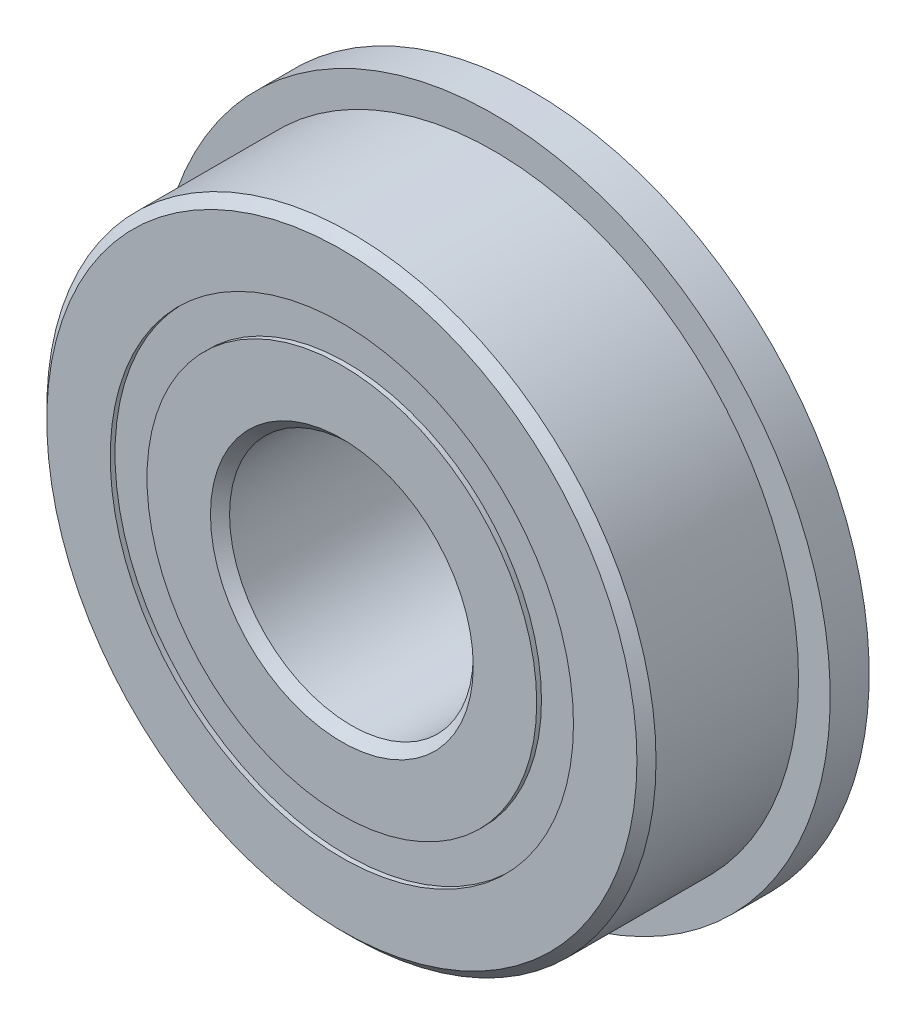
from build123d import *

# Parameters (mm, degrees)
CIRPATTERN1_COUNT = 14
SKETCH5_W         = 1.15919535
SKETCH5_H         = 0.957942858
SKETCH6_W         = 1.016
SKETCH6_H         = 2.727778571


with BuildPart() as part:
    # Sketch1 → Revolve1 (revolve)
    with BuildSketch(Plane(origin=(0, 0, 0), x_dir=(0, 0, -1), z_dir=(1, 0, 0)), mode=Mode.PRIVATE) as revolve1_sk:
        with BuildLine():
            Line((2.24028, 7.9375), (-2.24028, 7.9375))
            Line((-2.24028, 7.9375), (-2.4892, 7.68858))
            Line((-2.4892, 7.68858), (-2.4892, 6.035221429))
            Line((-2.4892, 6.035221429), (-1.106311111, 6.035221429))
            ThreePointArc((-1.106311111, 6.035221429), (0, 6.76179465), (1.106311111, 6.035221429))
            Line((1.106311111, 6.035221429), (2.4892, 6.035221429))
            Line((2.4892, 6.035221429), (2.4892, 7.68858))
            Line((2.4892, 7.68858), (2.24028, 7.9375))
        make_face()
    revolve(revolve1_sk.sketch.rotate(Axis((0, 0, 2.4892), (0, 0, -1)), 90), axis=Axis((0, 0, 2.4892), (0, 0, -1)))  # turned: the seam where the file's is

    # Sketch6 → Revolve6 (revolve)
    with BuildSketch(Plane(origin=(0, 0, 0), x_dir=(0, 0, -1), z_dir=(1, 0, 0)), mode=Mode.PRIVATE) as revolve6_sk:
        with Locations((1.9812, 7.399110715)):
            Rectangle(SKETCH6_W, SKETCH6_H)
    revolve(revolve6_sk.sketch.rotate(Axis((0, 0, -2.4892), (0, 0, 1)), 270), axis=Axis((0, 0, -2.4892), (0, 0, 1)))  # turned: the seam where the file's is


with BuildPart() as body_2:
    # Sketch3 → Revolve3 (revolve)
    with BuildSketch(Plane(origin=(0, 0, 0), x_dir=(0, 0, -1), z_dir=(1, 0, 0)), mode=Mode.PRIVATE) as revolve3_sk:
        with BuildLine():
            Line((-2.4892, 5.077278571), (-1.106311111, 5.077278571))
            ThreePointArc((-1.106311111, 5.077278571), (0, 4.35070535), (1.106311111, 5.077278571))
            Line((1.106311111, 5.077278571), (2.4892, 5.077278571))
            Line((2.4892, 5.077278571), (2.4892, 3.42392))
            Line((2.4892, 3.42392), (2.24028, 3.175))
            Line((2.24028, 3.175), (-2.24028, 3.175))
            Line((-2.24028, 3.175), (-2.4892, 3.42392))
            Line((-2.4892, 3.42392), (-2.4892, 5.077278571))
        make_face()
    revolve(revolve3_sk.sketch.rotate(Axis((0, 0, 2.4892), (0, 0, -1)), 90), axis=Axis((0, 0, 2.4892), (0, 0, -1)))  # turned: the seam where the file's is


with BuildPart() as body_3:
    # Sketch4 → Revolve4 (revolve)
    with BuildSketch(Plane(origin=(0, 0, 0), x_dir=(0, 0, -1), z_dir=(1, 0, 0))):
        with BuildLine():
            Line((-1.20554465, 5.55625), (1.20554465, 5.55625))
            ThreePointArc((1.20554465, 5.55625), (0, 6.76179465), (-1.20554465, 5.55625))
        make_face()
    revolve(axis=Axis((0, 5.55625, 1.20554465), (0, 0, -1)))


with BuildPart() as cirpattern1_1:
    # CirPattern1: pattern copy
    add(body_3.part.rotate(Axis((0, 0, 0), (0, 0, 1)), 1 * 360 / CIRPATTERN1_COUNT))


with BuildPart() as cirpattern1_2:
    # CirPattern1: pattern copy
    add(body_3.part.rotate(Axis((0, 0, 0), (0, 0, 1)), 2 * 360 / CIRPATTERN1_COUNT))


with BuildPart() as cirpattern1_3:
    # CirPattern1: pattern copy
    add(body_3.part.rotate(Axis((0, 0, 0), (0, 0, 1)), 3 * 360 / CIRPATTERN1_COUNT))


with BuildPart() as cirpattern1_4:
    # CirPattern1: pattern copy
    add(body_3.part.rotate(Axis((0, 0, 0), (0, 0, 1)), 4 * 360 / CIRPATTERN1_COUNT))


with BuildPart() as cirpattern1_5:
    # CirPattern1: pattern copy
    add(body_3.part.rotate(Axis((0, 0, 0), (0, 0, 1)), 5 * 360 / CIRPATTERN1_COUNT))


with BuildPart() as cirpattern1_6:
    # CirPattern1: pattern copy
    add(body_3.part.rotate(Axis((0, 0, 0), (0, 0, 1)), 6 * 360 / CIRPATTERN1_COUNT))


with BuildPart() as cirpattern1_7:
    # CirPattern1: pattern copy
    add(body_3.part.rotate(Axis((0, 0, 0), (0, 0, 1)), 7 * 360 / CIRPATTERN1_COUNT))


with BuildPart() as cirpattern1_8:
    # CirPattern1: pattern copy
    add(body_3.part.rotate(Axis((0, 0, 0), (0, 0, 1)), 8 * 360 / CIRPATTERN1_COUNT))


with BuildPart() as cirpattern1_9:
    # CirPattern1: pattern copy
    add(body_3.part.rotate(Axis((0, 0, 0), (0, 0, 1)), 9 * 360 / CIRPATTERN1_COUNT))


with BuildPart() as cirpattern1_10:
    # CirPattern1: pattern copy
    add(body_3.part.rotate(Axis((0, 0, 0), (0, 0, 1)), 10 * 360 / CIRPATTERN1_COUNT))


with BuildPart() as cirpattern1_11:
    # CirPattern1: pattern copy
    add(body_3.part.rotate(Axis((0, 0, 0), (0, 0, 1)), 11 * 360 / CIRPATTERN1_COUNT))


with BuildPart() as cirpattern1_12:
    # CirPattern1: pattern copy
    add(body_3.part.rotate(Axis((0, 0, 0), (0, 0, 1)), 12 * 360 / CIRPATTERN1_COUNT))


with BuildPart() as cirpattern1_13:
    # CirPattern1: pattern copy
    add(body_3.part.rotate(Axis((0, 0, 0), (0, 0, 1)), 13 * 360 / CIRPATTERN1_COUNT))


with BuildPart() as body_17:
    # Sketch5 → Revolve5 (revolve)
    with BuildSketch(Plane(origin=(0, 0, 0), x_dir=(0, 0, -1), z_dir=(1, 0, 0)), mode=Mode.PRIVATE) as revolve5_sk:
        with Locations((-1.785142325, 5.55625)):
            Rectangle(SKETCH5_W, SKETCH5_H)
        with Locations((1.785142325, 5.55625)):
            Rectangle(SKETCH5_W, SKETCH5_H)
    revolve(revolve5_sk.sketch.rotate(Axis((0, 0, 2.4892), (0, 0, -1)), 90), axis=Axis((0, 0, 2.4892), (0, 0, -1)))  # turned: the seam where the file's is


solid = Compound([part.part, body_2.part, body_3.part, cirpattern1_1.part, cirpattern1_2.part, cirpattern1_3.part, cirpattern1_4.part, cirpattern1_5.part, cirpattern1_6.part, cirpattern1_7.part, cirpattern1_8.part, cirpattern1_9.part, cirpattern1_10.part, cirpattern1_11.part, cirpattern1_12.part, cirpattern1_13.part, body_17.part])
